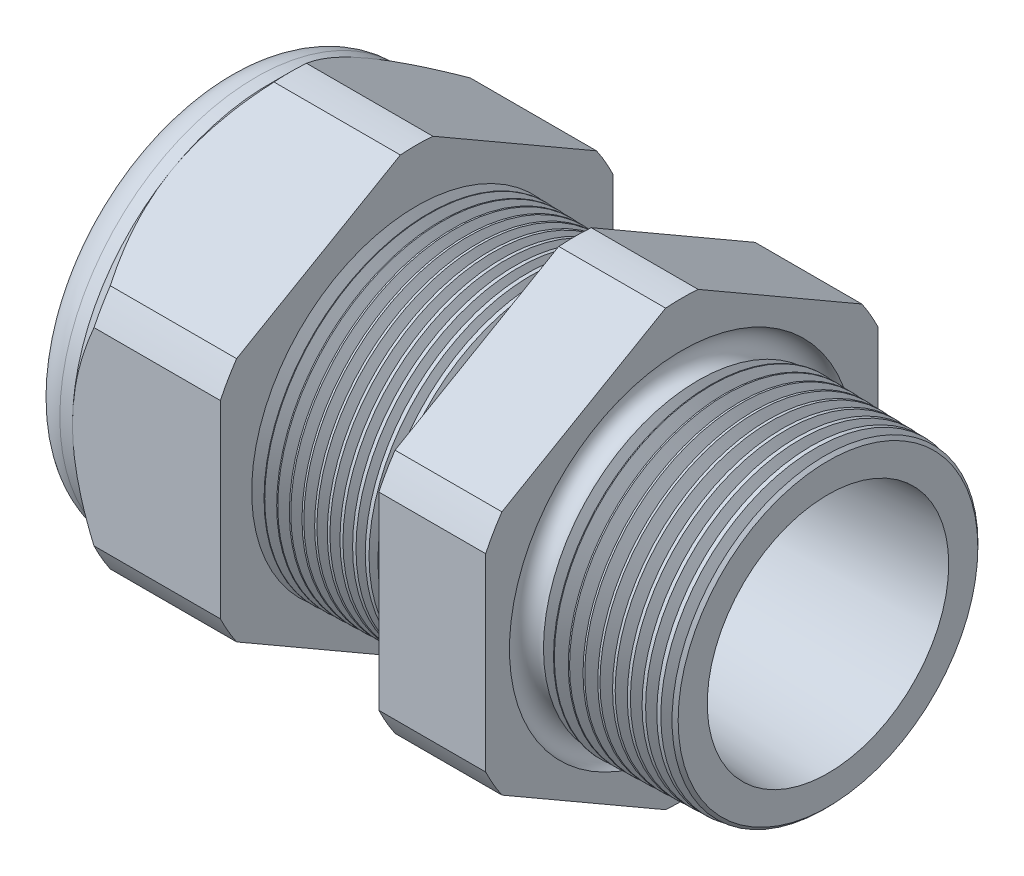
from build123d import *

# Parameters (mm, degrees)
SKETCH12_OUTSIDE_W = 65.136
SKETCH12_OUTSIDE_H = 65.136
CUT_EXTRUDE2_DEPTH = 35.03
FILLET4_R          = 2.032
SKETCH19_OUTSIDE_W = 40.13
SKETCH19_OUTSIDE_H = 42.756
SKETCH19_OUTSIDE_R = 11.938
CUT_EXTRUDE3_DEPTH = 1.999996
CUT_EXTRUDE3_DRAFT = -45
CHAMFER1_SIZE      = 0.260919487
CHAMFER1_SIZE2     = 0.254
SKETCH21_R         = 5.969
PLUG_DEPTH         = 6.35
SKETCH22_R         = 5.715
CUT_EXTRUDE4_DEPTH = 0.508
SKETCH27_R         = 1.524
PLUGHOLES_DEPTH    = 37.322
CIRPATTERN1_COUNT  = 6
LPATTERN1_COUNT    = 13
LPATTERN1_PITCH    = 0.762
LPATTERN2_COUNT    = 10
LPATTERN2_PITCH    = 0.889
SKETCH32_R         = 0.889


with BuildPart() as part:
    # Sketch10 → Revolve2 (revolve)
    with BuildSketch(Plane.XY, mode=Mode.PRIVATE) as revolve2_sk:
        Polygon((-35.814, 5.969), (-24.014, 5.969), (1.016, 7.345566383), (1.016, 9.377566383), (-7.874, 9.610359226), (-7.874, 23.876), (-14.374, 23.876), (-14.374, 9.780567716), (-24.014, 10.033), (-24.014, 23.876), (-33.014, 23.876), (-33.014, 11.938), (-35.814, 11.938), align=None)
    revolve(revolve2_sk.sketch.rotate(Axis((0, 0, 0), (-1, 0, 0)), 90), axis=Axis((0, 0, 0), (-1, 0, 0)))  # turned: the seam where the file's is

    # Sketch12 outside → Cut-Extrude2 (cut, through all)
    with BuildSketch(Plane.ZY.offset(33.014)):
        Rectangle(SKETCH12_OUTSIDE_W, SKETCH12_OUTSIDE_H)
        with BuildLine():
            Line((-0.98819228, 13.214281948), (-10.94980772, 7.462940592))
            ThreePointArc((-10.94980772, 7.462940592), (-11.47585851, 6.62559), (-11.938, 5.751341356))
            Line((-11.938, 5.751341356), (-11.938, -5.751341356))
            ThreePointArc((-11.938, -5.751341356), (-11.47585851, -6.62559), (-10.94980772, -7.462940592))
            Line((-10.94980772, -7.462940592), (-0.98819228, -13.214281948))
            ThreePointArc((-0.98819228, -13.214281948), (0, -13.25118), (0.98819228, -13.214281948))
            Line((0.98819228, -13.214281948), (10.94980772, -7.462940592))
            ThreePointArc((10.94980772, -7.462940592), (11.47585851, -6.62559), (11.938, -5.751341356))
            Line((11.938, -5.751341356), (11.938, 5.751341356))
            ThreePointArc((11.938, 5.751341356), (11.47585851, 6.62559), (10.94980772, 7.462940592))
            Line((10.94980772, 7.462940592), (0.98819228, 13.214281948))
            ThreePointArc((0.98819228, 13.214281948), (0, 13.25118), (-0.98819228, 13.214281948))
        make_face(mode=Mode.SUBTRACT)
    extrude(amount=-CUT_EXTRUDE2_DEPTH, mode=Mode.SUBTRACT)

    # Fillet4
    fillet4_edges = [part.edges().sort_by_distance(p)[0] for p in [
        (-35.814, 0, 11.938),
    ]]
    fillet(fillet4_edges, radius=FILLET4_R)


with BuildPart() as cut_extrude3_tool:
    # Sketch19 outside → Cut-Extrude3 (with draft: the straight prism first)
    with BuildSketch(Plane.ZY.offset(33.014)):
        Rectangle(SKETCH19_OUTSIDE_W, SKETCH19_OUTSIDE_H)
        Circle(SKETCH19_OUTSIDE_R, mode=Mode.SUBTRACT)
    extrude(amount=-CUT_EXTRUDE3_DEPTH)
    # Cut-Extrude3: the draft: its side faces are tilted about the plane it starts from
    cut_extrude3_sides = [cut_extrude3_tool.faces().sort_by_distance(p)[0] for p in [
        (-32.014002, -21.378, 0),
        (-32.014002, 0, 20.065),
        (-32.014002, 21.378, 0),
        (-32.014002, 0, -20.065),
        (-32.014002, 0, -11.938),
    ]]
    draft(cut_extrude3_sides, Plane.ZY.offset(33.014), CUT_EXTRUDE3_DRAFT)


with BuildPart() as part_1:
    add(part.part)

    # Cut-Extrude3: cut by cut_extrude3_tool
    add(cut_extrude3_tool.part, mode=Mode.SUBTRACT)

    # Chamfer1
    chamfer1_edges = [part_1.edges().sort_by_distance(p)[0] for p in [
        (1.016, 0, 9.377566383),
    ]]
    chamfer1_side = [part_1.faces().sort_by_distance(p)[0] for p in [
        (1.016, 0, 7.610804014),
    ]]
    chamfer(chamfer1_edges, length=CHAMFER1_SIZE, length2=CHAMFER1_SIZE2, reference=chamfer1_side[0])

    # Sketch29 → Cut-Revolve1 (revolve, cut)
    with BuildSketch(Plane.XY, mode=Mode.PRIVATE) as cut_revolve1_sk:
        Polygon((-24.014, 10.033), (-23.281016419, 10.013806149), (-23.664130572, 9.388620673), align=None)
    cut_revolve1 = revolve(cut_revolve1_sk.sketch.rotate(Axis((0, 0, 0), (-1, 0, 0)), 90), axis=Axis((0, 0, 0), (-1, 0, 0)), mode=Mode.SUBTRACT)  # turned: the seam where the file's is

    # LPattern1: Cut-Revolve1 ×13
    with Locations(*[(i * LPATTERN1_PITCH, 0, 0) for i in range(1, LPATTERN1_COUNT)]):
        add(cut_revolve1, mode=Mode.SUBTRACT)

    # Sketch30 → Cut-Revolve2 (revolve, cut)
    with BuildSketch(Plane.XY, mode=Mode.PRIVATE) as cut_revolve2_sk:
        Polygon((-7.874, 9.610359226), (-6.994419703, 9.587326605), (-7.454156686, 8.837104034), align=None)
    cut_revolve2 = revolve(cut_revolve2_sk.sketch.rotate(Axis((0, 0, 0), (-1, 0, 0)), 270), axis=Axis((0, 0, 0), (-1, 0, 0)), mode=Mode.SUBTRACT)  # turned: the seam where the file's is

    # LPattern2: Cut-Revolve2 ×10
    with Locations(*[(i * LPATTERN2_PITCH, 0, 0) for i in range(1, LPATTERN2_COUNT)]):
        add(cut_revolve2, mode=Mode.SUBTRACT)

    # Sketch32 → Cut-Revolve3 (revolve, cut)
    with BuildSketch(Plane.XY, mode=Mode.PRIVATE) as cut_revolve3_sk:
        with Locations((-7.747, 9.610359226)):
            Circle(SKETCH32_R)
    revolve(cut_revolve3_sk.sketch.rotate(Axis((0, 0, 0), (-1, 0, 0)), 270), axis=Axis((0, 0, 0), (-1, 0, 0)), mode=Mode.SUBTRACT)  # turned: the seam where the file's is


with BuildPart() as body_2:
    # Sketch21 → plug (new body)
    with BuildSketch(Plane.ZY.offset(35.814)):
        Circle(SKETCH21_R)
    extrude(amount=-PLUG_DEPTH)

    # Sketch22 → Cut-Extrude4 (cut)
    with BuildSketch(Plane.ZY.offset(35.814)):
        Circle(SKETCH22_R)
    extrude(amount=-CUT_EXTRUDE4_DEPTH, mode=Mode.SUBTRACT)

    # Sketch27 → plugholes (cut, through all)
    with BuildSketch(Plane.ZY.offset(35.306)):
        with Locations((-4.184904, 0)):
            Circle(SKETCH27_R)
    plugholes = extrude(amount=-PLUGHOLES_DEPTH, mode=Mode.SUBTRACT)

    # CirPattern1: plugholes ×6 about axis
    cirpattern1_axis = Axis((0, 0, 0), (1, 0, 0))
    for i in range(1, CIRPATTERN1_COUNT):
        add(plugholes.rotate(cirpattern1_axis, i * 360 / CIRPATTERN1_COUNT), mode=Mode.SUBTRACT)


solid = Compound([part_1.part, body_2.part])
